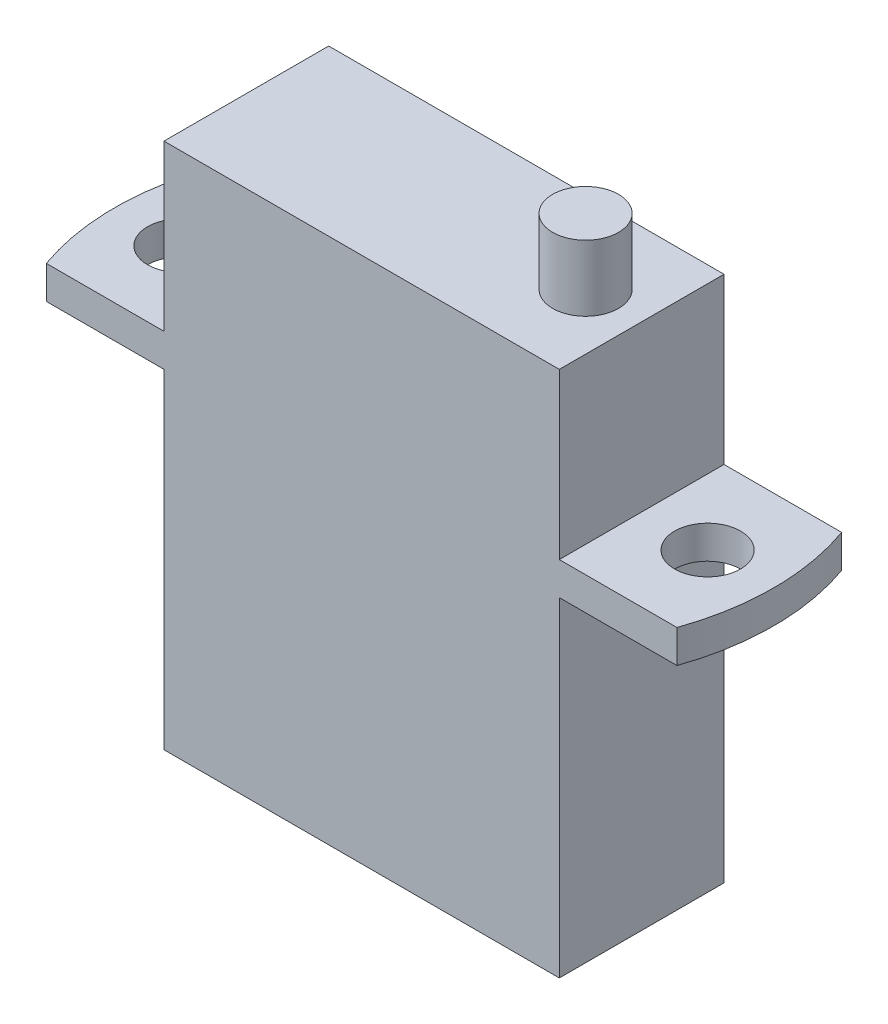
from build123d import *

# Parameters (mm, degrees)
SKETCH1_W           = 12
SKETCH1_H           = 5
BOSS_EXTRUDE1_DEPTH = 10
SKETCH2_R           = 1
SKETCH2_W           = 12
SKETCH2_H           = 5
BOSS_EXTRUDE2_DEPTH = 1
SKETCH3_W           = 12
SKETCH3_H           = 5
BOSS_EXTRUDE3_DEPTH = 5
SKETCH4_R           = 1
BOSS_EXTRUDE4_DEPTH = 2


with BuildPart() as part:
    # Sketch1 → Boss-Extrude1 (new body)
    with BuildSketch(Plane(origin=(0, 0, 0), x_dir=(1, 0, 0), z_dir=(0, 1, 0))):
        Rectangle(SKETCH1_W, SKETCH1_H)
    extrude(amount=-BOSS_EXTRUDE1_DEPTH)

    # Sketch2 → Boss-Extrude2 (add)
    with BuildSketch(Plane(origin=(0, 0, 0), x_dir=(1, 0, 0), z_dir=(0, 1, 0))):
        with BuildLine():
            Line((6, -2.5), (9.571067871, -2.5))
            ThreePointArc((9.571067871, -2.5), (10, 1e-08), (9.571067753, 2.5))
            Line((9.571067753, 2.5), (6, 2.5))
            Line((6, 2.5), (6, -2.5))
        make_face()
        with Locations((8, -5.35e-07)):
            Circle(SKETCH2_R, mode=Mode.SUBTRACT)
        Rectangle(SKETCH2_W, SKETCH2_H)
        with BuildLine():
            ThreePointArc((-9.571067871, -2.5), (-10, 1e-08), (-9.571067753, 2.5))
            Line((-9.571067753, 2.5), (-6, 2.5))
            Line((-6, 2.5), (-6, -2.5))
            Line((-6, -2.5), (-9.571067871, -2.5))
        make_face()
        with Locations((-8, -5.35e-07)):
            Circle(SKETCH2_R, mode=Mode.SUBTRACT)
    extrude(amount=BOSS_EXTRUDE2_DEPTH)

    # Sketch3 → Boss-Extrude3 (add)
    with BuildSketch(Plane(origin=(0, 1, 0), x_dir=(1, 0, 0), z_dir=(0, 1, 0))):
        Rectangle(SKETCH3_W, SKETCH3_H)
    extrude(amount=BOSS_EXTRUDE3_DEPTH)

    # Sketch4 → Boss-Extrude4 (add)
    with BuildSketch(Plane(origin=(0, 6, 0), x_dir=(1, 0, 0), z_dir=(0, 1, 0))):
        with Locations((4.297757617, 0)):
            Circle(SKETCH4_R)
    extrude(amount=BOSS_EXTRUDE4_DEPTH)


solid = part.part
